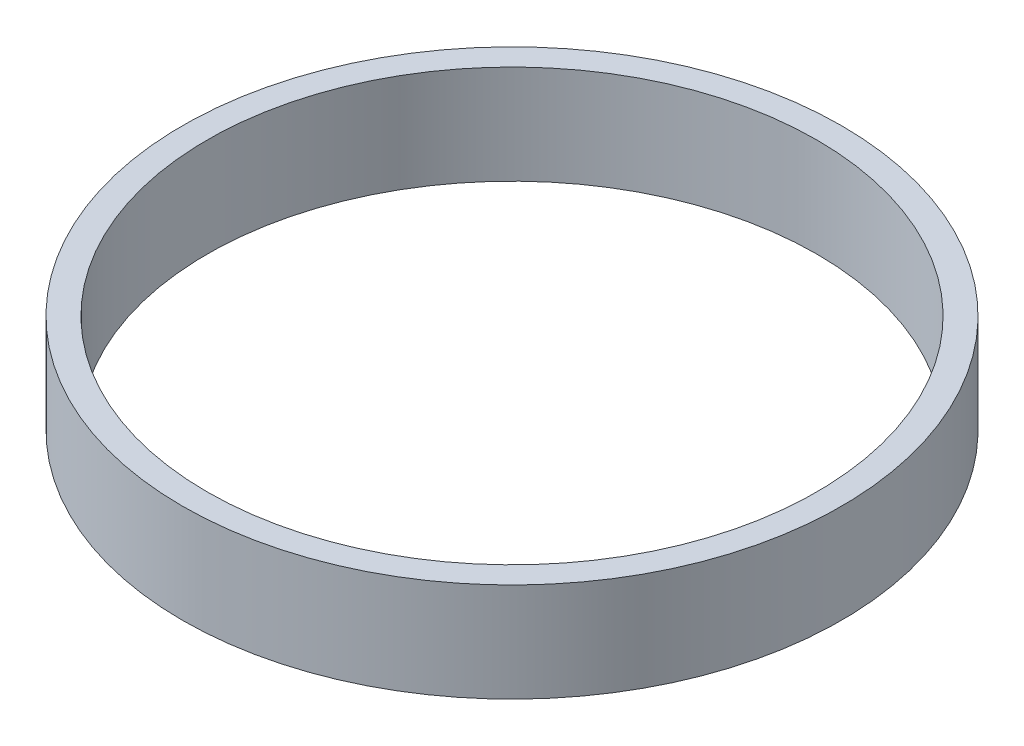
from build123d import *

# Parameters (mm, degrees)
SKETCH3_R           = 20
BOSS_EXTRUDE1_DEPTH = 6
SKETCH5_R           = 18.5
CUT_EXTRUDE1_DEPTH  = 6


with BuildPart() as part:
    # Sketch3 → Boss-Extrude1 (new body)
    with BuildSketch(Plane(origin=(0, 0, 0), x_dir=(1, 0, 0), z_dir=(0, 1, 0))):
        Circle(SKETCH3_R)
    extrude(amount=BOSS_EXTRUDE1_DEPTH)

    # Sketch5 → Cut-Extrude1 (cut)
    with BuildSketch(Plane(origin=(0, 6, 0), x_dir=(1, 0, 0), z_dir=(0, 1, 0))):
        Circle(SKETCH5_R)
    extrude(amount=-CUT_EXTRUDE1_DEPTH, mode=Mode.SUBTRACT)


solid = part.part
